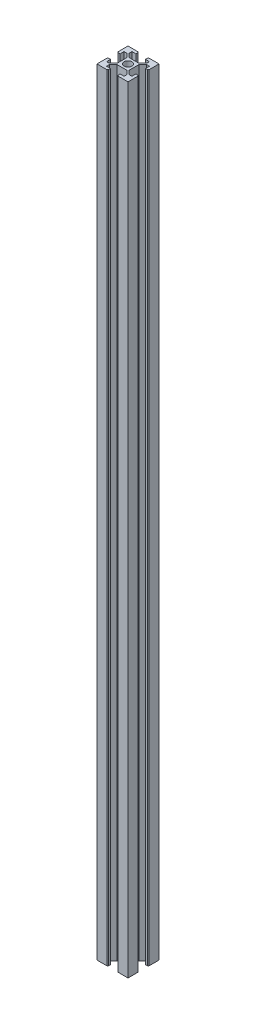
from build123d import *

# Parameters (mm, degrees)
SKETCH1_R           = 2.5
BOSS_EXTRUDE1_DEPTH = 500


with BuildPart() as part:
    # Sketch1 → Boss-Extrude1 (new body)
    with BuildSketch(Plane(origin=(0, 0, 0), x_dir=(1, 0, 0), z_dir=(0, 1, 0))):
        Polygon((3.9, 0), (3.9, 3.1), (6.425901812, 5.625901812), (8.163583062, 5.625901812), (8.163583062, 3.1), (9.5, 3.1), (10, 3.6), (10, 10), (3.6, 10), (3.1, 9.5), (3.1, 8.163583062), (5.625901812, 8.163583062), (5.625901812, 6.425901812), (3.1, 3.9), (0, 3.9), (-3.1, 3.9), (-5.625901812, 6.425901812), (-5.625901812, 8.163583062), (-3.1, 8.163583062), (-3.1, 9.5), (-3.6, 10), (-10, 10), (-10, 3.6), (-9.5, 3.1), (-8.163583062, 3.1), (-8.163583062, 5.625901812), (-6.425901812, 5.625901812), (-3.9, 3.1), (-3.9, 0), (-3.9, -3.1), (-6.425901812, -5.625901812), (-8.163583062, -5.625901812), (-8.163583062, -3.1), (-9.5, -3.1), (-10, -3.6), (-10, -10), (-3.6, -10), (-3.1, -9.5), (-3.1, -8.163583062), (-5.625901812, -8.163583062), (-5.625901812, -6.425901812), (-3.1, -3.9), (0, -3.9), (3.1, -3.9), (5.625901812, -6.425901812), (5.625901812, -8.163583062), (3.1, -8.163583062), (3.1, -9.5), (3.6, -10), (10, -10), (10, -3.6), (9.5, -3.1), (8.163583062, -3.1), (8.163583062, -5.625901812), (6.425901812, -5.625901812), (3.9, -3.1), align=None)
        Circle(SKETCH1_R, mode=Mode.SUBTRACT)
    extrude(amount=BOSS_EXTRUDE1_DEPTH)


solid = part.part
